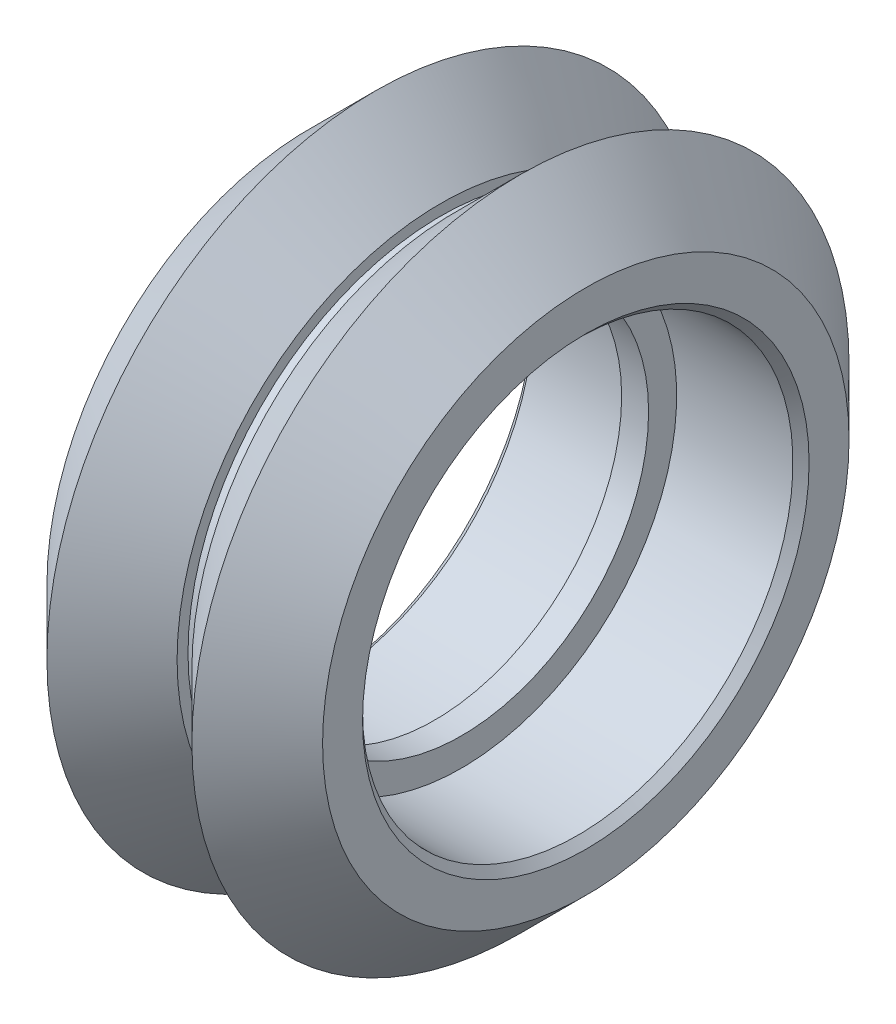
from build123d import *

# Parameters (mm, degrees)
CHAMFER1_SIZE = 0.3


with BuildPart() as part:
    # Sketch1 → Revolve1 (revolve)
    with BuildSketch(Plane.XY):
        Polygon((0.5, 6.945), (-0.5, 6.945), (-0.5, 7.987), (-5.115, 7.987), (-5.115, 9.77), (-2.69, 12.195), (-0.275, 9.78), (-0.275, 9.375), (0.275, 9.375), (0.275, 9.78), (2.69, 12.195), (5.115, 9.77), (5.115, 7.987), (0.5, 7.987), align=None)
    revolve(axis=Axis((0, 0, 0), (1, 0, 0)))

    # Chamfer1
    chamfer1_edges = [part.edges().sort_by_distance(p)[0] for p in [
        (-5.115, -7.987, 0),
        (5.115, -7.987, 0),
    ]]
    chamfer(chamfer1_edges, length=CHAMFER1_SIZE)


solid = part.part
